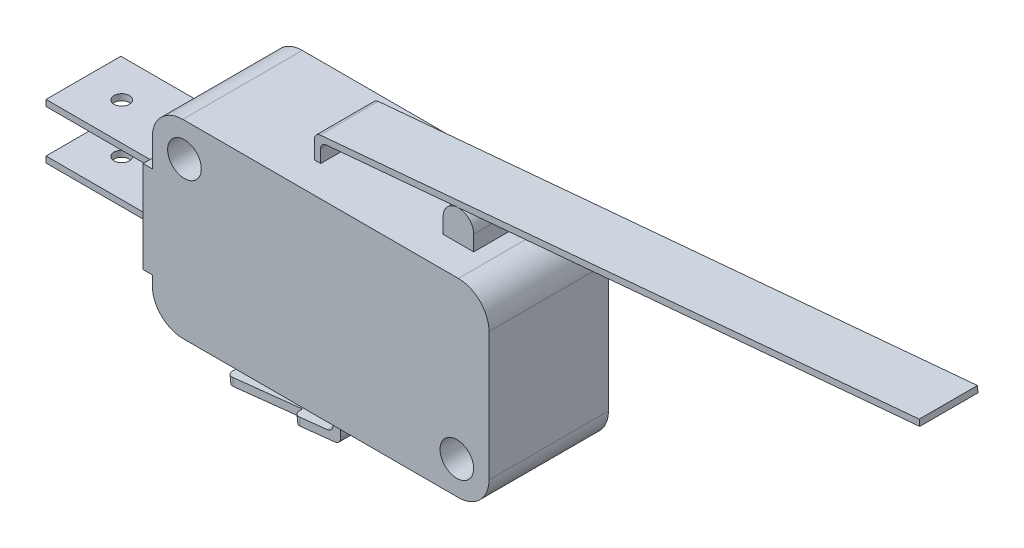
from build123d import *

# Parameters (mm, degrees)
SKETCH1_R      = 1.395
EXTRUDE1_DEPTH = 4.955
SKETCH2_W      = 9.906
SKETCH2_H      = 0.508
EXTRUDE2_DEPTH = 3.105
EXTRUDE3_DEPTH = 2.415
EXTRUDE4_DEPTH = 2.92
EXTRUDE5_REACH = 29.791
SKETCH5_W      = 6.351205797
SKETCH5_H      = 0.762
SKETCH5_H_2    = 0.76
EXTRUDE6_REACH = 29.791
SKETCH_R       = 0.762
FILLET1_R      = 0.508
SKETCH6_R      = 0.635
EXTRUDE7_DEPTH = 4.572
SKETCH_2_R     = 1.395
EXTRUDE8_DEPTH = 7.92


with BuildPart() as part:
    # Sketch1 → Extrude1 (new body, symmetric)
    with BuildSketch(Plane.XY):
        with Locations((-11.3, 5.08)):
            Circle(SKETCH1_R)
        with BuildLine():
            Line((13.97, -5.334), (13.97, 5.334))
            ThreePointArc((13.97, 5.334), (13.226051224, 7.130051224), (11.43, 7.874))
            Line((11.43, 7.874), (-11.43, 7.874))
            ThreePointArc((-11.43, 7.874), (-13.226051224, 7.130051224), (-13.97, 5.334))
            Line((-13.97, 5.334), (-13.97, 3.048))
            Line((-13.97, 3.048), (-14.732, 3.048))
            Line((-14.732, 3.048), (-14.732, -4.572))
            Line((-14.732, -4.572), (-13.97, -4.572))
            Line((-13.97, -4.572), (-13.97, -5.334))
            ThreePointArc((-13.97, -5.334), (-13.226051224, -7.130051224), (-11.43, -7.874))
            Line((-11.43, -7.874), (11.43, -7.874))
            ThreePointArc((11.43, -7.874), (13.226051224, -7.130051224), (13.97, -5.334))
        make_face()
        with Locations((11.3, -5.16)):
            Circle(SKETCH1_R, mode=Mode.SUBTRACT)
        with Locations((-11.3, 5.08)):
            Circle(SKETCH1_R, mode=Mode.SUBTRACT)
        with Locations((11.3, -5.16)):
            Circle(SKETCH1_R)
    extrude(amount=EXTRUDE1_DEPTH, both=True)

    # Sketch2 → Extrude2 (add, symmetric)
    with BuildSketch(Plane.XY):
        with Locations((-19.685, -2.54)):
            Rectangle(SKETCH2_W, SKETCH2_H)
        with Locations((-19.685, 1.524)):
            Rectangle(SKETCH2_W, SKETCH2_H)
    extrude(amount=EXTRUDE2_DEPTH, both=True)

    # Sketch3 → Extrude3 (add, symmetric)
    with BuildSketch(Plane.XY):
        Polygon((47.128347754, 14.344963285), (-3.048, 9.862642591), (-3.048, 7.874), (-2.54, 7.874), (-2.54, 9.398), (47.173548085, 13.838978176), align=None)
        with BuildLine():
            Line((10.16, 7.874), (10.16, 9.139))
            ThreePointArc((10.16, 9.139), (8.89, 10.409), (7.62, 9.139))
            Line((7.62, 9.139), (7.62, 7.874))
            Line((7.62, 7.874), (10.16, 7.874))
        make_face()
    extrude(amount=EXTRUDE3_DEPTH, both=True)

    # Sketch4 → Extrude4 (add, symmetric)
    with BuildSketch(Plane.XY):
        Polygon((-0.38, -10.984), (-0.38, -7.874), (-1.015, -7.874), (-1.015, -10.414), (-10.612457197, -11.452431876), (-10.54414973, -12.083747241), align=None)
    extrude(amount=EXTRUDE4_DEPTH, both=True)

    # Sketch5 → Extrude5 (cut, up to next)
    with BuildSketch(Plane(origin=(1.170304596, -10.816259141, 0), x_dir=(0.994197425, 0.107570815, 0), z_dir=(0.107570815, -0.994197425, 0)), mode=Mode.PRIVATE) as extrude5_sk1:
        with Locations((-8.607222155, 2.539)):
            Rectangle(SKETCH5_W, SKETCH5_H)
    extrude5_tool1 = extrude(extrude5_sk1.sketch, amount=-EXTRUDE5_REACH, mode=Mode.PRIVATE) & part.part
    add(extrude5_tool1.solids().sort_by_distance((-7.386974, -11.742145, 2.539))[0], mode=Mode.SUBTRACT)
    # Sketch5 → Extrude5 (cut, up to next)
    with BuildSketch(Plane(origin=(1.170304596, -10.816259141, 0), x_dir=(0.994197425, 0.107570815, 0), z_dir=(0.107570815, -0.994197425, 0)), mode=Mode.PRIVATE) as extrude5_sk2:
        with Locations((-8.607222155, -2.54)):
            Rectangle(SKETCH5_W, SKETCH5_H_2)
    extrude5_tool2 = extrude(extrude5_sk2.sketch, amount=-EXTRUDE5_REACH, mode=Mode.PRIVATE) & part.part
    add(extrude5_tool2.solids().sort_by_distance((-7.386974, -11.742145, -2.54))[0], mode=Mode.SUBTRACT)

    # Sketch → Extrude6 (cut, up to next)
    with BuildSketch(Plane(origin=(1.170304596, -10.816259141, 0), x_dir=(0.994197425, 0.107570815, 0), z_dir=(0.107570815, -0.994197425, 0)), mode=Mode.PRIVATE) as extrude6_sk1:
        with Locations((-8.101824296, 0)):
            Circle(SKETCH_R)
    extrude6_tool1 = extrude(extrude6_sk1.sketch, amount=-EXTRUDE6_REACH, mode=Mode.PRIVATE) & part.part
    add(extrude6_tool1.solids().sort_by_distance((-6.884508, -11.687779, 0))[0], mode=Mode.SUBTRACT)

    # Fillet1
    fillet1_edges = [part.edges().sort_by_distance(p)[0] for p in [
        (-4.263951014, -11.084885172, 2.92),
        (-10.578303464, -11.768089558, 2.158),
        (-10.578303464, -11.768089558, -2.16),
        (-4.263951014, -11.084885172, -2.92),
        (-3.048, 9.862642591, 0),
        (-2.54, 9.398, 0),
        (-0.38, -10.984, 0),
        (-1.015, -10.414, 0),
    ]]
    fillet(fillet1_edges, radius=FILLET1_R)

    # Sketch6 → Extrude7 (cut)
    with BuildSketch(Plane.XZ.offset(2.794)):
        with Locations((-21.462, 0)):
            Circle(SKETCH6_R)
    extrude(amount=-EXTRUDE7_DEPTH, mode=Mode.SUBTRACT)

    # Sketch 2 → Extrude8 (cut, symmetric)
    with BuildSketch(Plane.XY):
        with Locations((-11.3, 5.08)):
            Circle(SKETCH_2_R)
        with Locations((11.3, -5.16)):
            Circle(SKETCH_2_R)
    extrude(amount=EXTRUDE8_DEPTH, both=True, mode=Mode.SUBTRACT)


solid = part.part
